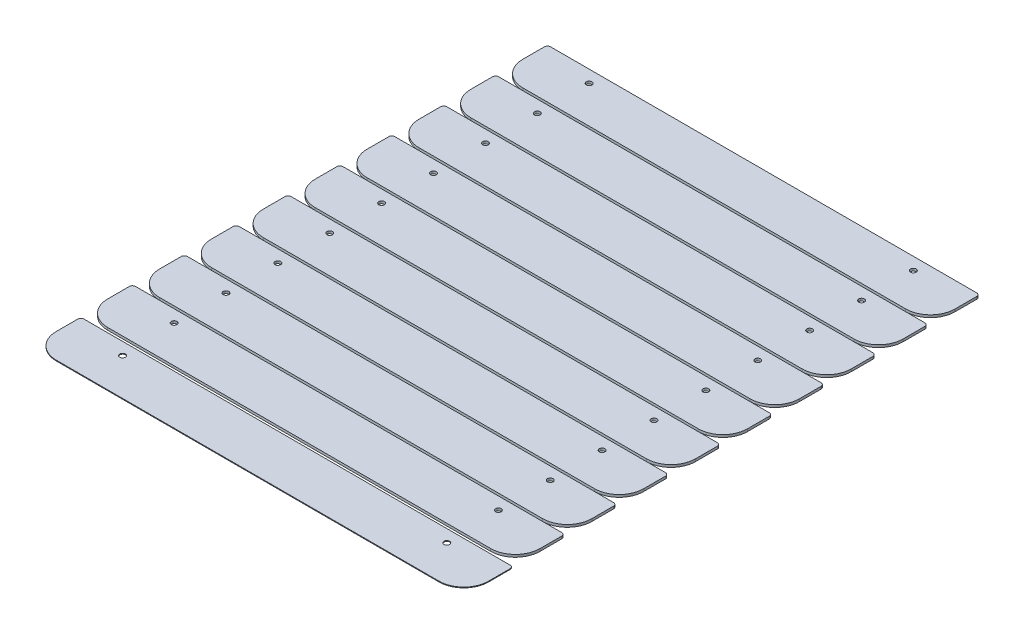
from build123d import *

# Parameters (mm, degrees)
SKETCH1_W                  = 444.5
SKETCH1_H                  = 50.8
BOSS_EXTRUDE1_DEPTH        = 0.79375
FILLET1_R                  = 25.4
FILLET2_R                  = 3.175
F_1_0_228_DIAMETER_HOLE1_D = 5.7912
SKETCH4_R                  = 2.8956
BOSS_EXTRUDE2_DEPTH        = 2.54
BOSS_EXTRUDE2_2_DEPTH      = 2.54
BOSS_EXTRUDE2_3_DEPTH      = 2.54
BOSS_EXTRUDE2_4_DEPTH      = 2.54
BOSS_EXTRUDE2_5_DEPTH      = 2.54
BOSS_EXTRUDE2_6_DEPTH      = 2.54
BOSS_EXTRUDE2_7_DEPTH      = 2.54
BOSS_EXTRUDE2_8_DEPTH      = 2.54
BOSS_EXTRUDE2_9_DEPTH      = 2.54


with BuildPart() as part:
    # Sketch1 → Boss-Extrude1 (new body)
    with BuildSketch(Plane(origin=(0, 0, 0), x_dir=(1, 0, 0), z_dir=(0, 1, 0))):
        Rectangle(SKETCH1_W, SKETCH1_H)
    extrude(amount=BOSS_EXTRUDE1_DEPTH)

    # Fillet1
    fillet1_edges = [part.edges().sort_by_distance(p)[0] for p in [
        (222.25, 0.396875, 25.4),
        (-222.25, 0.396875, 25.4),
    ]]
    fillet(fillet1_edges, radius=FILLET1_R)

    # Fillet2
    fillet2_edges = [part.edges().sort_by_distance(p)[0] for p in [
        (-222.25, 0.396875, -25.4),
        (222.25, 0.396875, -25.4),
    ]]
    fillet(fillet2_edges, radius=FILLET2_R)

    # #1 (0.228) Diameter Hole1 (through all)
    with Locations(Plane(origin=(0, 0.79375, 0), x_dir=(1, 0, 0), z_dir=(0, 1, 0))):
        with Locations((166.6875, 12.7), (-166.6875, 12.7)):
            Hole(F_1_0_228_DIAMETER_HOLE1_D / 2)


with BuildPart() as body_2:
    # Sketch4 → Boss-Extrude2 (new body)
    with BuildSketch(Plane(origin=(0, 0.79375, 0), x_dir=(1, 0, 0), z_dir=(0, 1, 0))):
        with BuildLine():
            Line((222.25, 52.998363175), (222.25, 75.223363175))
            ThreePointArc((222.25, 75.223363175), (221.32006403, 77.468427205), (219.075, 78.398363175))
            Line((219.075, 78.398363175), (-219.075, 78.398363175))
            ThreePointArc((-219.075, 78.398363175), (-221.32006403, 77.468427205), (-222.25, 75.223363175))
            Line((-222.25, 75.223363175), (-222.25, 52.998363175))
            ThreePointArc((-222.25, 52.998363175), (-214.810512242, 35.037850933), (-196.85, 27.598363175))
            Line((-196.85, 27.598363175), (196.85, 27.598363175))
            ThreePointArc((196.85, 27.598363175), (214.810512242, 35.037850933), (222.25, 52.998363175))
        make_face()
        with Locations((-166.6875, 65.698363175)):
            Circle(SKETCH4_R, mode=Mode.SUBTRACT)
        with Locations((166.6875, 65.698363175)):
            Circle(SKETCH4_R, mode=Mode.SUBTRACT)
    extrude(amount=BOSS_EXTRUDE2_DEPTH)


with BuildPart() as body_3:
    # Sketch4 → Boss-Extrude2 2 (new body)
    with BuildSketch(Plane(origin=(0, 0.79375, 0), x_dir=(1, 0, 0), z_dir=(0, 1, 0))):
        with BuildLine():
            Line((222.25, 106.338363175), (222.25, 128.563363175))
            ThreePointArc((222.25, 128.563363175), (221.32006403, 130.808427205), (219.075, 131.738363175))
            Line((219.075, 131.738363175), (-219.075, 131.738363175))
            ThreePointArc((-219.075, 131.738363175), (-221.32006403, 130.808427205), (-222.25, 128.563363175))
            Line((-222.25, 128.563363175), (-222.25, 106.338363175))
            ThreePointArc((-222.25, 106.338363175), (-214.810512242, 88.377850933), (-196.85, 80.938363175))
            Line((-196.85, 80.938363175), (196.85, 80.938363175))
            ThreePointArc((196.85, 80.938363175), (214.810512242, 88.377850933), (222.25, 106.338363175))
        make_face()
        with Locations((-166.6875, 119.038363175)):
            Circle(SKETCH4_R, mode=Mode.SUBTRACT)
        with Locations((166.6875, 119.038363175)):
            Circle(SKETCH4_R, mode=Mode.SUBTRACT)
    extrude(amount=BOSS_EXTRUDE2_2_DEPTH)


with BuildPart() as body_4:
    # Sketch4 → Boss-Extrude2 3 (new body)
    with BuildSketch(Plane(origin=(0, 0.79375, 0), x_dir=(1, 0, 0), z_dir=(0, 1, 0))):
        with BuildLine():
            Line((222.25, 159.678363175), (222.25, 181.903363175))
            ThreePointArc((222.25, 181.903363175), (221.32006403, 184.148427205), (219.075, 185.078363175))
            Line((219.075, 185.078363175), (-219.075, 185.078363175))
            ThreePointArc((-219.075, 185.078363175), (-221.32006403, 184.148427205), (-222.25, 181.903363175))
            Line((-222.25, 181.903363175), (-222.25, 159.678363175))
            ThreePointArc((-222.25, 159.678363175), (-214.810512242, 141.717850933), (-196.85, 134.278363175))
            Line((-196.85, 134.278363175), (196.85, 134.278363175))
            ThreePointArc((196.85, 134.278363175), (214.810512242, 141.717850933), (222.25, 159.678363175))
        make_face()
        with Locations((-166.6875, 172.378363175)):
            Circle(SKETCH4_R, mode=Mode.SUBTRACT)
        with Locations((166.6875, 172.378363175)):
            Circle(SKETCH4_R, mode=Mode.SUBTRACT)
    extrude(amount=BOSS_EXTRUDE2_3_DEPTH)


with BuildPart() as body_5:
    # Sketch4 → Boss-Extrude2 4 (new body)
    with BuildSketch(Plane(origin=(0, 0.79375, 0), x_dir=(1, 0, 0), z_dir=(0, 1, 0))):
        with BuildLine():
            Line((222.25, 213.018363175), (222.25, 235.243363175))
            ThreePointArc((222.25, 235.243363175), (221.32006403, 237.488427205), (219.075, 238.418363175))
            Line((219.075, 238.418363175), (-219.075, 238.418363175))
            ThreePointArc((-219.075, 238.418363175), (-221.32006403, 237.488427205), (-222.25, 235.243363175))
            Line((-222.25, 235.243363175), (-222.25, 213.018363175))
            ThreePointArc((-222.25, 213.018363175), (-214.810512242, 195.057850933), (-196.85, 187.618363175))
            Line((-196.85, 187.618363175), (196.85, 187.618363175))
            ThreePointArc((196.85, 187.618363175), (214.810512242, 195.057850933), (222.25, 213.018363175))
        make_face()
        with Locations((-166.6875, 225.718363175)):
            Circle(SKETCH4_R, mode=Mode.SUBTRACT)
        with Locations((166.6875, 225.718363175)):
            Circle(SKETCH4_R, mode=Mode.SUBTRACT)
    extrude(amount=BOSS_EXTRUDE2_4_DEPTH)


with BuildPart() as body_6:
    # Sketch4 → Boss-Extrude2 5 (new body)
    with BuildSketch(Plane(origin=(0, 0.79375, 0), x_dir=(1, 0, 0), z_dir=(0, 1, 0))):
        with BuildLine():
            Line((222.25, 266.358363175), (222.25, 288.583363175))
            ThreePointArc((222.25, 288.583363175), (221.32006403, 290.828427205), (219.075, 291.758363175))
            Line((219.075, 291.758363175), (-219.075, 291.758363175))
            ThreePointArc((-219.075, 291.758363175), (-221.32006403, 290.828427205), (-222.25, 288.583363175))
            Line((-222.25, 288.583363175), (-222.25, 266.358363175))
            ThreePointArc((-222.25, 266.358363175), (-214.810512242, 248.397850933), (-196.85, 240.958363175))
            Line((-196.85, 240.958363175), (196.85, 240.958363175))
            ThreePointArc((196.85, 240.958363175), (214.810512242, 248.397850933), (222.25, 266.358363175))
        make_face()
        with Locations((-166.6875, 279.058363175)):
            Circle(SKETCH4_R, mode=Mode.SUBTRACT)
        with Locations((166.6875, 279.058363175)):
            Circle(SKETCH4_R, mode=Mode.SUBTRACT)
    extrude(amount=BOSS_EXTRUDE2_5_DEPTH)


with BuildPart() as body_7:
    # Sketch4 → Boss-Extrude2 6 (new body)
    with BuildSketch(Plane(origin=(0, 0.79375, 0), x_dir=(1, 0, 0), z_dir=(0, 1, 0))):
        with BuildLine():
            Line((222.25, 319.698363175), (222.25, 341.923363175))
            ThreePointArc((222.25, 341.923363175), (221.32006403, 344.168427205), (219.075, 345.098363175))
            Line((219.075, 345.098363175), (-219.075, 345.098363175))
            ThreePointArc((-219.075, 345.098363175), (-221.32006403, 344.168427205), (-222.25, 341.923363175))
            Line((-222.25, 341.923363175), (-222.25, 319.698363175))
            ThreePointArc((-222.25, 319.698363175), (-214.810512242, 301.737850933), (-196.85, 294.298363175))
            Line((-196.85, 294.298363175), (196.85, 294.298363175))
            ThreePointArc((196.85, 294.298363175), (214.810512242, 301.737850933), (222.25, 319.698363175))
        make_face()
        with Locations((-166.6875, 332.398363175)):
            Circle(SKETCH4_R, mode=Mode.SUBTRACT)
        with Locations((166.6875, 332.398363175)):
            Circle(SKETCH4_R, mode=Mode.SUBTRACT)
    extrude(amount=BOSS_EXTRUDE2_6_DEPTH)


with BuildPart() as body_8:
    # Sketch4 → Boss-Extrude2 7 (new body)
    with BuildSketch(Plane(origin=(0, 0.79375, 0), x_dir=(1, 0, 0), z_dir=(0, 1, 0))):
        with BuildLine():
            Line((222.25, 373.038363175), (222.25, 395.263363175))
            ThreePointArc((222.25, 395.263363175), (221.32006403, 397.508427205), (219.075, 398.438363175))
            Line((219.075, 398.438363175), (-219.075, 398.438363175))
            ThreePointArc((-219.075, 398.438363175), (-221.32006403, 397.508427205), (-222.25, 395.263363175))
            Line((-222.25, 395.263363175), (-222.25, 373.038363175))
            ThreePointArc((-222.25, 373.038363175), (-214.810512242, 355.077850933), (-196.85, 347.638363175))
            Line((-196.85, 347.638363175), (196.85, 347.638363175))
            ThreePointArc((196.85, 347.638363175), (214.810512242, 355.077850933), (222.25, 373.038363175))
        make_face()
        with Locations((-166.6875, 385.738363175)):
            Circle(SKETCH4_R, mode=Mode.SUBTRACT)
        with Locations((166.6875, 385.738363175)):
            Circle(SKETCH4_R, mode=Mode.SUBTRACT)
    extrude(amount=BOSS_EXTRUDE2_7_DEPTH)


with BuildPart() as body_9:
    # Sketch4 → Boss-Extrude2 8 (new body)
    with BuildSketch(Plane(origin=(0, 0.79375, 0), x_dir=(1, 0, 0), z_dir=(0, 1, 0))):
        with BuildLine():
            Line((222.25, 426.378363175), (222.25, 448.603363175))
            ThreePointArc((222.25, 448.603363175), (221.32006403, 450.848427205), (219.075, 451.778363175))
            Line((219.075, 451.778363175), (-219.075, 451.778363175))
            ThreePointArc((-219.075, 451.778363175), (-221.32006403, 450.848427205), (-222.25, 448.603363175))
            Line((-222.25, 448.603363175), (-222.25, 426.378363175))
            ThreePointArc((-222.25, 426.378363175), (-214.810512242, 408.417850933), (-196.85, 400.978363175))
            Line((-196.85, 400.978363175), (196.85, 400.978363175))
            ThreePointArc((196.85, 400.978363175), (214.810512242, 408.417850933), (222.25, 426.378363175))
        make_face()
        with Locations((-166.6875, 439.078363175)):
            Circle(SKETCH4_R, mode=Mode.SUBTRACT)
        with Locations((166.6875, 439.078363175)):
            Circle(SKETCH4_R, mode=Mode.SUBTRACT)
    extrude(amount=BOSS_EXTRUDE2_8_DEPTH)


with BuildPart() as body_10:
    # Sketch4 → Boss-Extrude2 9 (new body)
    with BuildSketch(Plane(origin=(0, 0.79375, 0), x_dir=(1, 0, 0), z_dir=(0, 1, 0))):
        with BuildLine():
            Line((222.25, 479.718363175), (222.25, 501.943363175))
            ThreePointArc((222.25, 501.943363175), (221.32006403, 504.188427205), (219.075, 505.118363175))
            Line((219.075, 505.118363175), (-219.075, 505.118363175))
            ThreePointArc((-219.075, 505.118363175), (-221.32006403, 504.188427205), (-222.25, 501.943363175))
            Line((-222.25, 501.943363175), (-222.25, 479.718363175))
            ThreePointArc((-222.25, 479.718363175), (-214.810512242, 461.757850933), (-196.85, 454.318363175))
            Line((-196.85, 454.318363175), (196.85, 454.318363175))
            ThreePointArc((196.85, 454.318363175), (214.810512242, 461.757850933), (222.25, 479.718363175))
        make_face()
        with Locations((-166.6875, 492.418363175)):
            Circle(SKETCH4_R, mode=Mode.SUBTRACT)
        with Locations((166.6875, 492.418363175)):
            Circle(SKETCH4_R, mode=Mode.SUBTRACT)
    extrude(amount=BOSS_EXTRUDE2_9_DEPTH)


solid = Compound([part.part, body_2.part, body_3.part, body_4.part, body_5.part, body_6.part, body_7.part, body_8.part, body_9.part, body_10.part])
